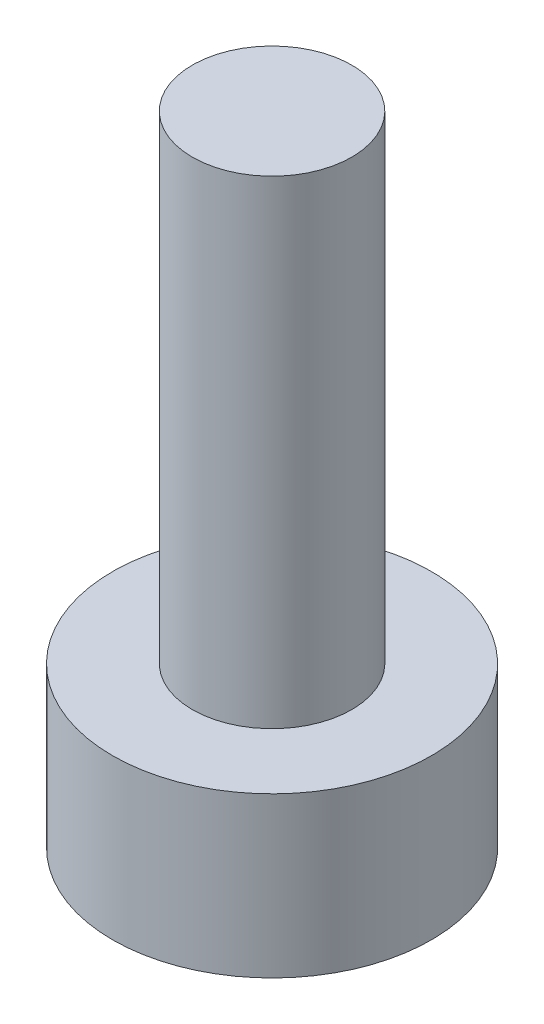
from build123d import *

# Parameters (mm, degrees)
SKETCH1_R           = 2
BOSS_EXTRUDE1_DEPTH = 2
SKETCH1_3_R         = 1
BOSS_EXTRUDE2_DEPTH = 8


with BuildPart() as part:
    # Sketch1 → Boss-Extrude1 (new body)
    with BuildSketch(Plane(origin=(0, 0, 0), x_dir=(1, 0, 0), z_dir=(0, 1, 0))):
        Circle(SKETCH1_R)
    extrude(amount=BOSS_EXTRUDE1_DEPTH)

    # Sketch1_3 → Boss-Extrude2 (add)
    with BuildSketch(Plane(origin=(0, 0, 0), x_dir=(1, 0, 0), z_dir=(0, 1, 0))):
        Circle(SKETCH1_3_R)
    extrude(amount=BOSS_EXTRUDE2_DEPTH)


solid = part.part
